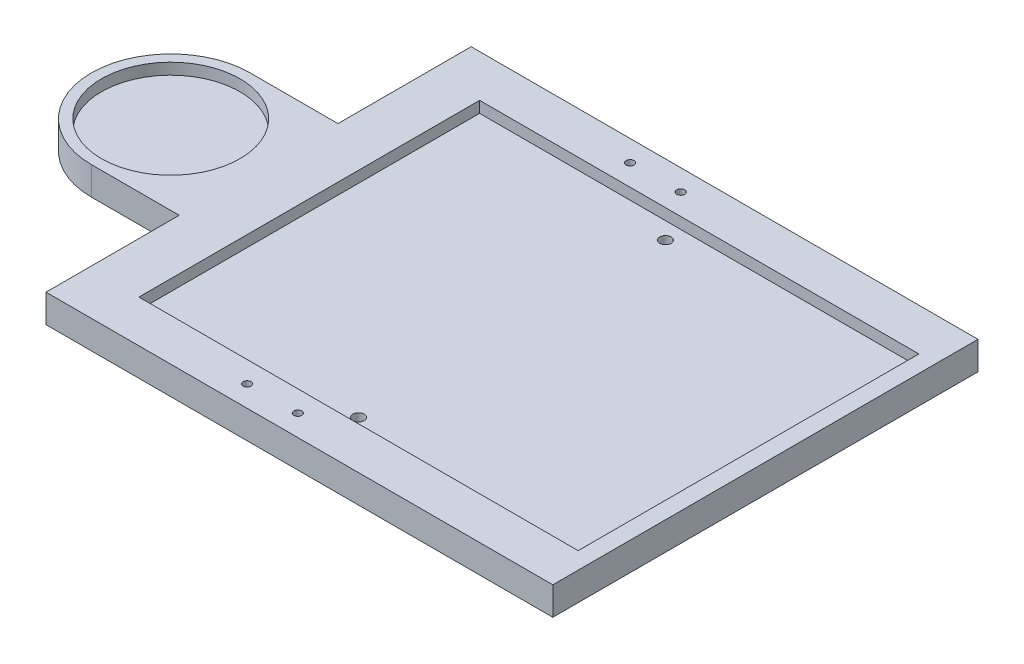
from build123d import *

# Parameters (mm, degrees)
SKETCH1_R           = 61.5
SKETCH1_W           = 390
SKETCH1_H           = 302.5
BOSS_EXTRUDE1_DEPTH = 25
SKETCH1_4_W         = 390
SKETCH1_4_H         = 302.5
SKETCH1_4_R         = 5
SKETCH1_4_R_2       = 61.5
BOSS_EXTRUDE2_DEPTH = 15
SKETCH3_R           = 3.5
CUT_EXTRUDE1_DEPTH  = 26


with BuildPart() as part:
    # Sketch1 → Boss-Extrude1 (new body)
    with BuildSketch(Plane(origin=(0, 0, 0), x_dir=(1, 0, 0), z_dir=(0, 1, 0))):
        with BuildLine():
            Line((0, 188.75), (450, 188.75))
            Line((450, 188.75), (450, -188.75))
            Line((450, -188.75), (0, -188.75))
            Line((0, -188.75), (0, -70.5))
            Line((0, -70.5), (-78, -70.5))
            ThreePointArc((-78, -70.5), (-148.5, 0), (-78, 70.5))
            Line((-78, 70.5), (0, 70.5))
            Line((0, 70.5), (0, 188.75))
        make_face()
        with Locations((-78, 0)):
            Circle(SKETCH1_R, mode=Mode.SUBTRACT)
        with Locations((240, 0)):
            Rectangle(SKETCH1_W, SKETCH1_H, mode=Mode.SUBTRACT)
    extrude(amount=BOSS_EXTRUDE1_DEPTH)

    # Sketch1_4 → Boss-Extrude2 (add)
    with BuildSketch(Plane(origin=(0, 0, 0), x_dir=(1, 0, 0), z_dir=(0, 1, 0))):
        with Locations((240, 0)):
            Rectangle(SKETCH1_4_W, SKETCH1_4_H)
        with Locations((225, 136.25)):
            Circle(SKETCH1_4_R, mode=Mode.SUBTRACT)
        with Locations((225, -136.25)):
            Circle(SKETCH1_4_R, mode=Mode.SUBTRACT)
        with Locations((-78, 0)):
            Circle(SKETCH1_4_R_2)
    extrude(amount=BOSS_EXTRUDE2_DEPTH)

    # Sketch3 → Cut-Extrude1 (cut, through all)
    with BuildSketch(Plane(origin=(0, 25, 0), x_dir=(1, 0, 0), z_dir=(0, 1, 0))):
        with Locations((159.81, -170)):
            Circle(SKETCH3_R)
        with Locations((204.81, -170)):
            Circle(SKETCH3_R)
        with Locations((204.81, 170)):
            Circle(SKETCH3_R)
        with Locations((159.81, 170)):
            Circle(SKETCH3_R)
    extrude(amount=-CUT_EXTRUDE1_DEPTH, mode=Mode.SUBTRACT)


solid = part.part
